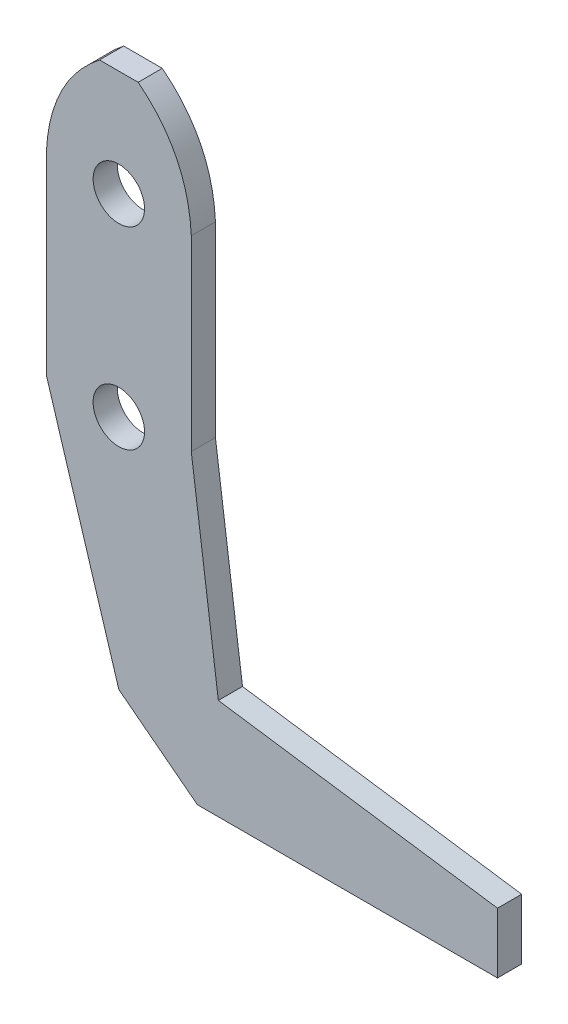
from build123d import *

# Parameters (mm, degrees)
SKETCH1_R           = 3.3782
BOSS_EXTRUDE1_DEPTH = 3.175
SCALE1_SCALE        = 0.35


with BuildPart() as part:
    # Sketch1 → Boss-Extrude1 (new body)
    with BuildSketch(Plane.XY):
        with BuildLine():
            Line((-2.54, 39.37), (2.54, 39.37))
            add(Edge.make_bspline(
                [(2.54, 39.37), (9.095418915, 34.201637521), (9.525, 25.4)],
                knots=[0, 0, 0, 1, 1, 1], degree=2))
            Line((9.525, 25.4), (9.525, 0.833077402))
            Line((9.525, 0.833077402), (13.080713372, -25.725670045))
            Line((13.080713372, -25.725670045), (49.772779476, -31.025635149))
            Line((49.772779476, -31.025635149), (49.772779476, -38.975582805))
            Line((49.772779476, -38.975582805), (10.326960053, -38.975582805))
            Line((10.326960053, -38.975582805), (0, -31.025635149))
            Line((0, -31.025635149), (-9.525, 0))
            Line((-9.525, 0), (-9.525, 25.4))
            add(Edge.make_bspline(
                [(-2.54, 39.37), (-9.095418915, 34.201637521), (-9.525, 25.4)],
                knots=[0, 0, 0, 1, 1, 1], degree=2))
        make_face()
        with Locations((0, 25.4)):
            Circle(SKETCH1_R, mode=Mode.SUBTRACT)
        Circle(SKETCH1_R, mode=Mode.SUBTRACT)
    extrude(amount=BOSS_EXTRUDE1_DEPTH)


with BuildPart() as part_1:
    # Scale1: scaled about (8.755454484, -6.947922753, 1.5875)
    add(part.part.scale(SCALE1_SCALE).moved(Location((5.691045415, -4.516149789, 1.031875))))


solid = part_1.part
